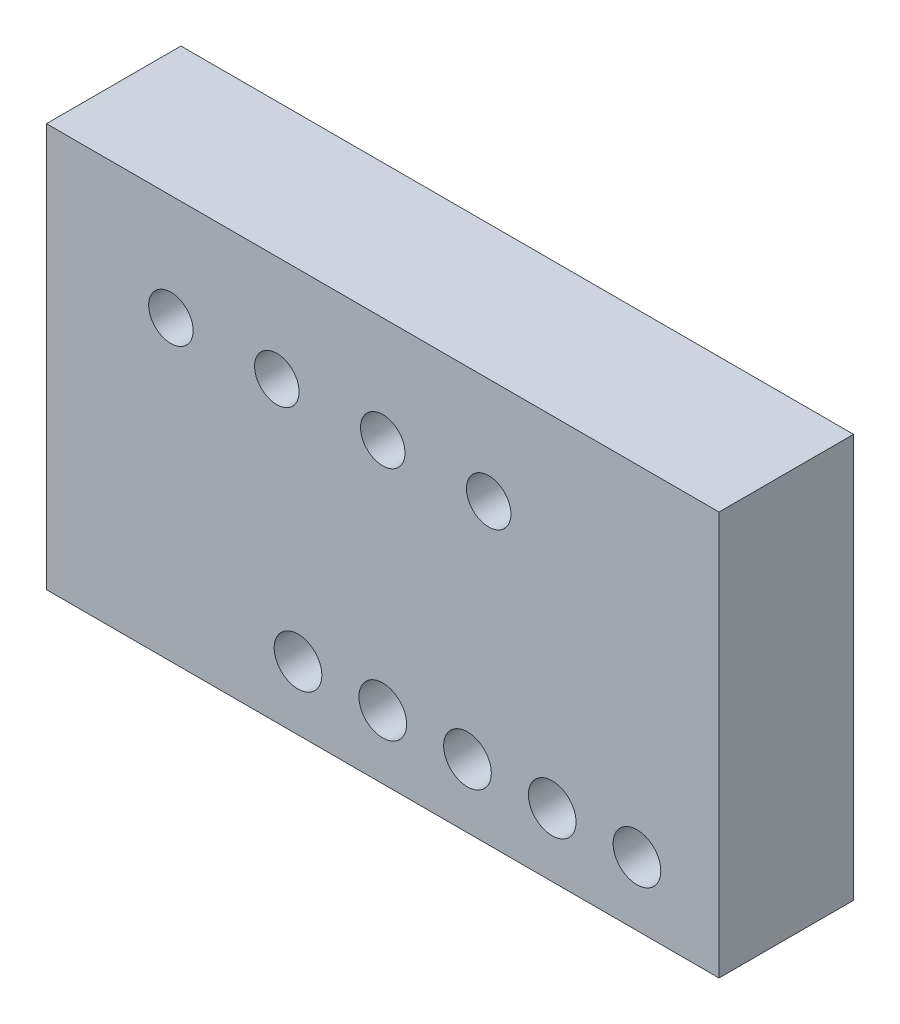
from build123d import *

# Parameters (mm, degrees)
SKETCH1_W             = 63.5
SKETCH1_H             = 38.1
BOSS_EXTRUDE1_DEPTH   = 12.7
M4_CLEARANCE_HOLE1_D  = 4.5
M5X0_8_TAPPED_HOLE1_D = 4.2


with BuildPart() as part:
    # Sketch1 → Boss-Extrude1 (new body)
    with BuildSketch(Plane.XY):
        Rectangle(SKETCH1_W, SKETCH1_H)
    extrude(amount=BOSS_EXTRUDE1_DEPTH)

    # M4 Clearance Hole1 (through all)
    with Locations(Plane.XY.offset(12.7)):
        with Locations((-8, -13.05), (0, -13.05), (8, -13.05), (16, -13.05), (24, -13.05)):
            Hole(M4_CLEARANCE_HOLE1_D / 2)

    # M5x0.8 Tapped Hole1 (through all)
    with Locations(Plane.XY.offset(12.7)):
        with Locations((-20, 9.05), (-10, 9.05), (0, 9.05), (10, 9.05)):
            Hole(M5X0_8_TAPPED_HOLE1_D / 2)


solid = part.part
